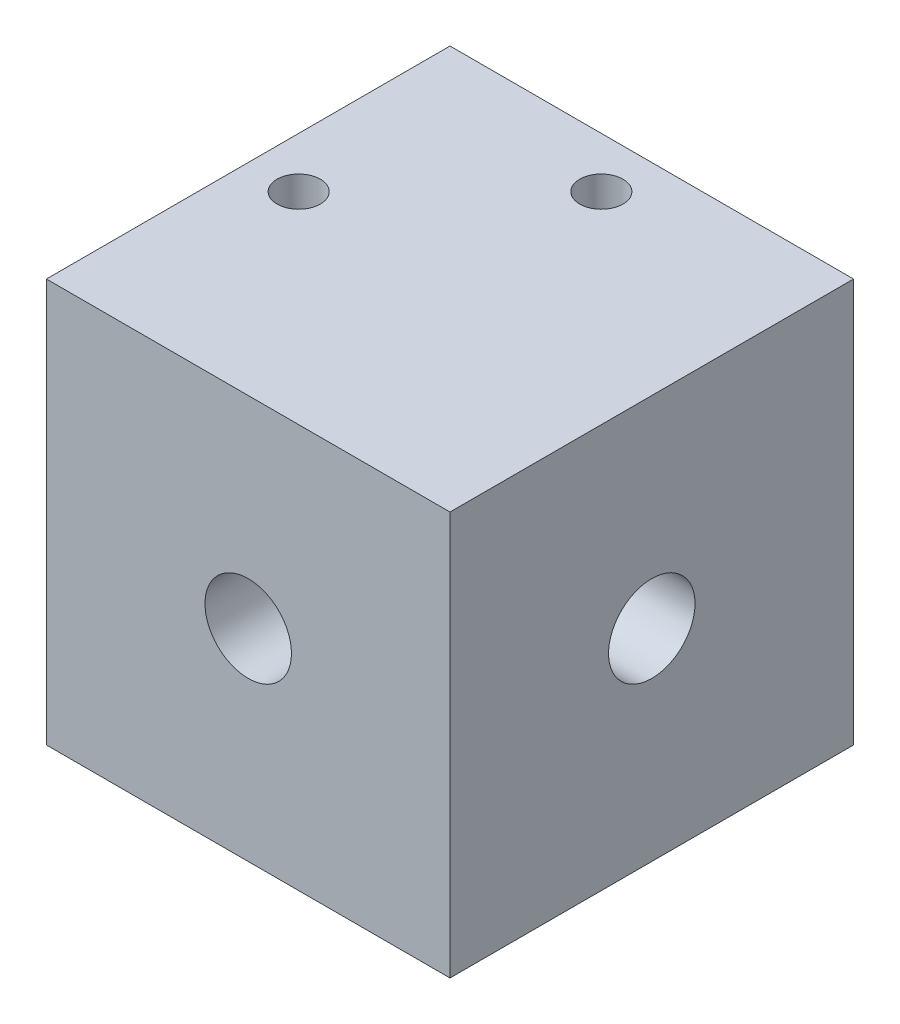
from build123d import *

# Parameters (mm, degrees)
CROQUIS1_W              = 28
CROQUIS1_H              = 28
SALIENTE_EXTRUIR1_DEPTH = 28
CROQUIS4_R              = 3.175
CORTAR_EXTRUIR3_DEPTH   = 10
CROQUIS6_R              = 3
CORTAR_EXTRUIR4_DEPTH   = 10
CROQUIS8_R              = 3.175
CORTAR_EXTRUIR5_DEPTH   = 10
CROQUIS9_R              = 3
CORTAR_EXTRUIR6_DEPTH   = 10
CROQUIS10_R             = 1.5
CORTAR_EXTRUIR7_DEPTH   = 12


with BuildPart() as part:
    # Croquis1 → Saliente-Extruir1 (new body)
    with BuildSketch(Plane.XY):
        with Locations((14, 14)):
            Rectangle(CROQUIS1_W, CROQUIS1_H)
    extrude(amount=SALIENTE_EXTRUIR1_DEPTH)

    # Croquis4 → Cortar-Extruir3 (cut)
    with BuildSketch(Plane.ZY):
        with Locations((14, 14)):
            Circle(CROQUIS4_R)
    extrude(amount=-CORTAR_EXTRUIR3_DEPTH, mode=Mode.SUBTRACT)

    # Croquis6 → Cortar-Extruir4 (cut)
    with BuildSketch(Plane(origin=(28, 0, 0), x_dir=(0, 0, -1), z_dir=(1, 0, 0))):
        with Locations((-14, 14)):
            Circle(CROQUIS6_R)
    extrude(amount=-CORTAR_EXTRUIR4_DEPTH, mode=Mode.SUBTRACT)

    # Croquis8 → Cortar-Extruir5 (cut)
    with BuildSketch(Plane(origin=(0, 0, 0), x_dir=(-1, 0, 0), z_dir=(0, 0, -1))):
        with Locations((-14, 14)):
            Circle(CROQUIS8_R)
    extrude(amount=-CORTAR_EXTRUIR5_DEPTH, mode=Mode.SUBTRACT)

    # Croquis9 → Cortar-Extruir6 (cut)
    with BuildSketch(Plane.XY.offset(28)):
        with Locations((14, 14)):
            Circle(CROQUIS9_R)
    extrude(amount=-CORTAR_EXTRUIR6_DEPTH, mode=Mode.SUBTRACT)

    # Croquis10 → Cortar-Extruir7 (cut)
    with BuildSketch(Plane(origin=(0, 28, 0), x_dir=(1, 0, 0), z_dir=(0, 1, 0))):
        with Locations((3.5, -14)):
            Circle(CROQUIS10_R)
        with Locations((14, -3.5)):
            Circle(CROQUIS10_R)
    extrude(amount=-CORTAR_EXTRUIR7_DEPTH, mode=Mode.SUBTRACT)


solid = part.part
